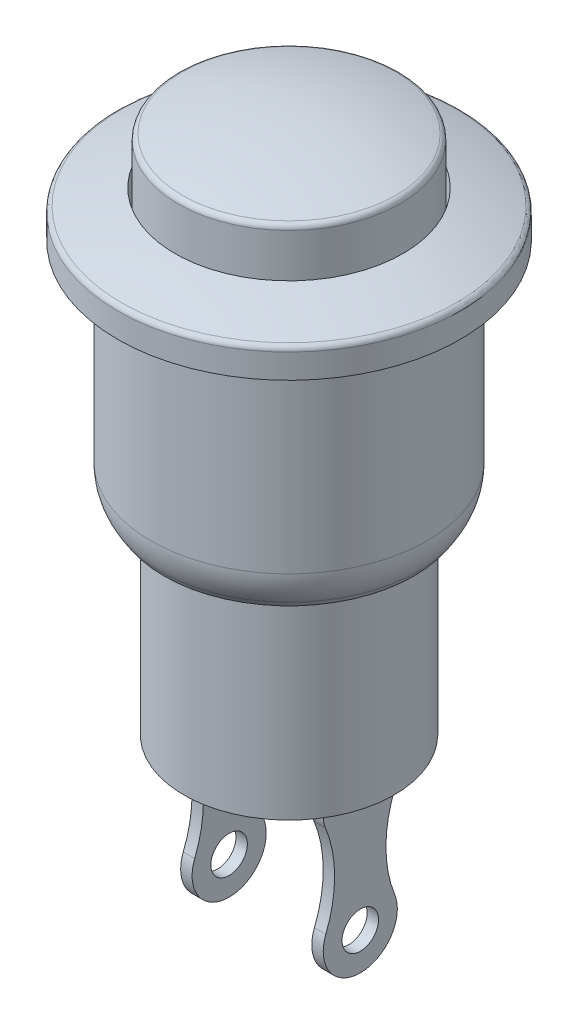
from build123d import *

# Parameters (mm, degrees)
CONG_1_R                = 0.2
CONG_2_R                = 0.2
CHANFREIN1_SIZE         = 0.7
CHANFREIN1_SIZE2        = 0.454585315
CONG_3_R                = 2
ESQUISSE2_W             = 0.4
ESQUISSE2_H             = 2.6
BOSS_EXTRU_1_DEPTH      = 6
ESQUISSE3_R             = 0.64
ENL_V_MAT_EXTRU_1_DEPTH = 6
CONG_4_R                = 1


with BuildPart() as part:
    # Esquisse1 → Révolution1 (revolve)
    with BuildSketch(Plane.XY):
        with BuildLine():
            Line((0, 18.8), (0, 0))
            Line((0, 0), (3.69, 0))
            Line((3.69, 0), (3.69, 7))
            Line((3.69, 7), (4.84, 7))
            Line((4.84, 7), (4.84, 15))
            Line((4.84, 15), (6.01, 15))
            Line((6.01, 15), (6.01, 16))
            ThreePointArc((6.01, 16), (5.013982948, 16.330092875), (4, 16.6))
            Line((4, 16.6), (4, 15.013190638))
            Line((4, 15.013190638), (3.89, 15.013190638))
            Line((3.89, 15.013190638), (3.89, 18.2))
            ThreePointArc((3.89, 18.2), (1.968000254, 18.649118314), (0, 18.8))
        make_face()
    revolve(axis=Axis((0, 0, 0), (0, 1, 0)))

    # Congé1
    cong_1_edges = [part.edges().sort_by_distance(p)[0] for p in [
        (-3.89, 18.2, 0),
    ]]
    fillet(cong_1_edges, radius=CONG_1_R)

    # Congé2
    cong_2_edges = [part.edges().sort_by_distance(p)[0] for p in [
        (-6.01, 16, 0),
    ]]
    fillet(cong_2_edges, radius=CONG_2_R)

    # Chanfrein1
    chanfrein1_edges = [part.edges().sort_by_distance(p)[0] for p in [
        (-4.84, 7, 0),
    ]]
    chanfrein1_side = [part.faces().sort_by_distance(p)[0] for p in [
        (-4.84, 11, 0),
    ]]
    chamfer(chanfrein1_edges, length=CHANFREIN1_SIZE, length2=CHANFREIN1_SIZE2, reference=chanfrein1_side[0])

    # Congé3
    cong_3_edges = [part.edges().sort_by_distance(p)[0] for p in [
        (-4.84, 7.7, 0),
    ]]
    fillet(cong_3_edges, radius=CONG_3_R)

    # Esquisse2 → Boss.-Extru.1 (add)
    with BuildSketch(Plane.XZ):
        with Locations((2.3, 0)):
            Rectangle(ESQUISSE2_W, ESQUISSE2_H)
        with Locations((-2.3, 0)):
            Rectangle(ESQUISSE2_W, ESQUISSE2_H)
    extrude(amount=BOSS_EXTRU_1_DEPTH)

    # Esquisse3 → Enlèv. mat.-Extru.1 (cut)
    with BuildSketch(Plane.ZY.offset(2.5)):
        with Locations((0, -4.7)):
            Circle(ESQUISSE3_R)
        with BuildLine():
            Line((-1.3, -0.8), (-4.192462756, -0.8))
            Line((-4.192462756, -0.8), (-4.192462756, -7.475627282))
            Line((-4.192462756, -7.475627282), (5.572809524, -7.57510374))
            Line((5.572809524, -7.57510374), (5.225347222, -0.8))
            Line((5.225347222, -0.8), (1.3, -0.8))
            ThreePointArc((1.3, -0.8), (0.901580438, -2.499750503), (1.207561262, -4.218548238))
            ThreePointArc((1.207561262, -4.218548238), (0, -6), (-1.207561262, -4.218548238))
            ThreePointArc((-1.207561262, -4.218548238), (-0.901580438, -2.499750503), (-1.3, -0.8))
        make_face()
    extrude(amount=-ENL_V_MAT_EXTRU_1_DEPTH, mode=Mode.SUBTRACT)

    # Congé4
    cong_4_edges = [part.edges().sort_by_distance(p)[0] for p in [
        (-2.3, -0.8, 1.3),
        (-2.3, -0.8, -1.3),
        (2.3, -0.8, -1.3),
        (2.3, -0.8, 1.3),
    ]]
    fillet(cong_4_edges, radius=CONG_4_R)


solid = part.part
